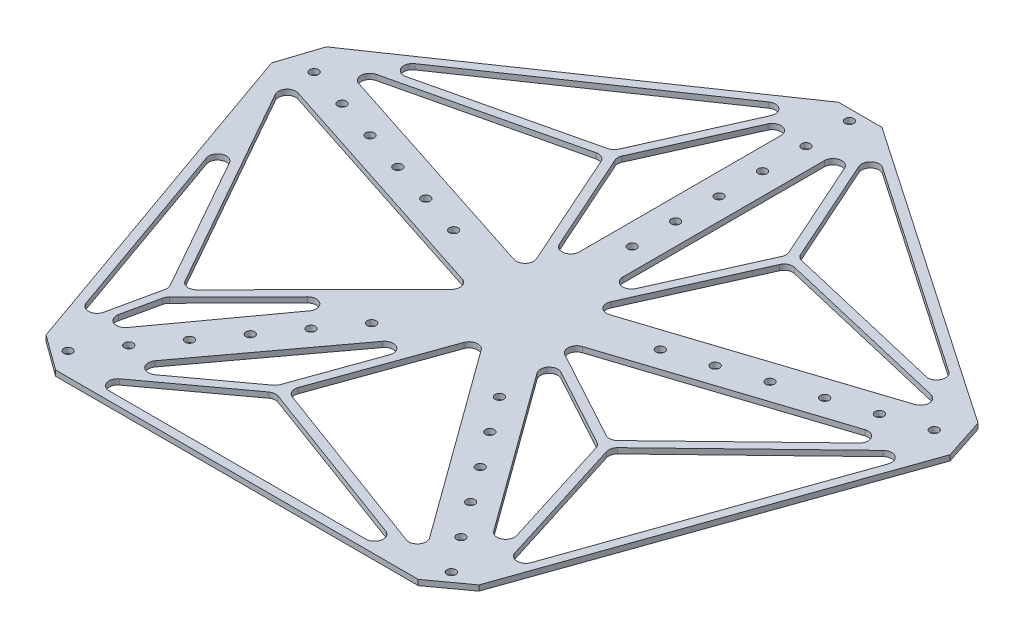
from build123d import *

# Parameters (mm, degrees)
BOSS_EXTRUDE2_DEPTH = 3.175
CUT_EXTRUDE6_START  = 3.175
SKETCH4_R           = 2.54
CUT_EXTRUDE6_DEPTH  = 4.175
CUT_EXTRUDE13_START = 3.175
CUT_EXTRUDE13_DEPTH = 4.175


with BuildPart() as part:
    # Sketch5 → Boss-Extrude2 (new body)
    with BuildSketch(Plane(origin=(0, 0, 0), x_dir=(1, 0, 0), z_dir=(0, 1, 0))):
        Polygon((-12.7, 196.799011925), (12.7, 196.799011925), (190.398728244, 75.217867192), (198.247759901, 51.061031678), (126.494099545, -152.497661128), (105.945067888, -167.427406536), (-105.945067888, -167.427406536), (-126.494099545, -152.497661128), (-198.247759901, 51.061031678), (-190.398728244, 75.217867192), align=None)
    extrude(amount=BOSS_EXTRUDE2_DEPTH)

    # Sketch4 → Cut-Extrude6 (cut, through all)
    with BuildSketch(Plane(origin=(0, 0, 0), x_dir=(1, 0, 0), z_dir=(0, 1, 0)).offset(CUT_EXTRUDE6_START)):
        with Locations((0, 63.5)):
            Circle(SKETCH4_R)
        with Locations((60.392088785, 19.622579143)):
            Circle(SKETCH4_R)
        with Locations((37.324363521, -51.372579143)):
            Circle(SKETCH4_R)
        with Locations((-37.324363521, -51.372579143)):
            Circle(SKETCH4_R)
        with Locations((-60.392088785, 19.622579143)):
            Circle(SKETCH4_R)
        with Locations((0, 88.9)):
            Circle(SKETCH4_R)
        with Locations((0, 114.3)):
            Circle(SKETCH4_R)
        with Locations((0, 139.7)):
            Circle(SKETCH4_R)
        with Locations((0, 165.1)):
            Circle(SKETCH4_R)
        with Locations((0, 190.5)):
            Circle(SKETCH4_R)
        with Locations((84.548924299, 27.4716108)):
            Circle(SKETCH4_R)
        with Locations((108.705759813, 35.320642457)):
            Circle(SKETCH4_R)
        with Locations((132.862595326, 43.169674114)):
            Circle(SKETCH4_R)
        with Locations((157.01943084, 51.018705771)):
            Circle(SKETCH4_R)
        with Locations((181.176266354, 58.867737428)):
            Circle(SKETCH4_R)
        with Locations((52.254108929, -71.9216108)):
            Circle(SKETCH4_R)
        with Locations((67.183854337, -92.470642457)):
            Circle(SKETCH4_R)
        with Locations((82.113599745, -113.019674114)):
            Circle(SKETCH4_R)
        with Locations((97.043345153, -133.568705771)):
            Circle(SKETCH4_R)
        with Locations((111.973090562, -154.117737428)):
            Circle(SKETCH4_R)
        with Locations((-52.254108929, -71.9216108)):
            Circle(SKETCH4_R)
        with Locations((-67.183854337, -92.470642457)):
            Circle(SKETCH4_R)
        with Locations((-82.113599745, -113.019674114)):
            Circle(SKETCH4_R)
        with Locations((-97.043345153, -133.568705771)):
            Circle(SKETCH4_R)
        with Locations((-111.973090562, -154.117737428)):
            Circle(SKETCH4_R)
        with Locations((-84.548924299, 27.4716108)):
            Circle(SKETCH4_R)
        with Locations((-108.705759813, 35.320642457)):
            Circle(SKETCH4_R)
        with Locations((-132.862595326, 43.169674114)):
            Circle(SKETCH4_R)
        with Locations((-157.01943084, 51.018705771)):
            Circle(SKETCH4_R)
        with Locations((-181.176266354, 58.867737428)):
            Circle(SKETCH4_R)
    extrude(amount=-CUT_EXTRUDE6_DEPTH, mode=Mode.SUBTRACT)

    # Sketch7 → Cut-Extrude13 (cut, through all)
    with BuildSketch(Plane(origin=(0, 0, 0), x_dir=(1, 0, 0), z_dir=(0, 1, 0)).offset(CUT_EXTRUDE13_START)):
        with BuildLine():
            Line((-156.047041019, 92.565980885), (-33.192300571, 176.622969516))
            ThreePointArc((-33.192300571, 176.622969516), (-27.068067962, 176.329998491), (-25.68635922, 170.356478756))
            Line((-25.68635922, 170.356478756), (-53.203019711, 108.827512556))
            ThreePointArc((-53.203019711, 108.827512556), (-54.602287787, 106.987211346), (-56.672188684, 105.957565789))
            Line((-56.672188684, 105.957565789), (-152.01026864, 83.429543359))
            ThreePointArc((-152.01026864, 83.429543359), (-157.825138498, 86.320353355), (-156.047041019, 92.565980885))
        make_face()
        with BuildLine():
            Line((-162.317570458, 66.093745934), (-27.928166645, 22.427981671))
            ThreePointArc((-27.928166645, 22.427981671), (-22.580875797, 23.862731232), (-21.720361584, 29.331875681))
            Line((-21.720361584, 29.331875681), (-52.204230458, 97.55011911))
            ThreePointArc((-52.204230458, 97.55011911), (-54.590345473, 100.031208318), (-58.010442561, 100.421444699))
            Line((-58.010442561, 100.421444699), (-161.9159775, 75.868965534))
            ThreePointArc((-161.9159775, 75.868965534), (-165.823482552, 71.133637537), (-162.317570458, 66.093745934))
        make_face()
        with BuildLine():
            Line((-12.7, 45.417267794), (-12.7, 163.148827455))
            ThreePointArc((-12.7, 163.148827455), (-16.719693987, 168.116940895), (-22.417382346, 165.222733185))
            Line((-22.417382346, 165.222733185), (-48.732523081, 106.380439974))
            ThreePointArc((-48.732523081, 106.380439974), (-49.175140679, 104.307289406), (-48.733139465, 102.234007335))
            Line((-48.733139465, 102.234007335), (-22.41799873, 43.344740886))
            ThreePointArc((-22.41799873, 43.344740886), (-16.720432528, 40.44899679), (-12.7, 45.417267794))
        make_face()
        with BuildLine():
            Line((162.102822693, 75.93291253), (57.996487946, 100.40450036))
            ThreePointArc((57.996487946, 100.40450036), (54.579506885, 100.011587225), (52.196050577, 97.531813783))
            Line((52.196050577, 97.531813783), (21.720361584, 29.331875681))
            ThreePointArc((21.720361584, 29.331875681), (22.580875797, 23.862731232), (27.928166645, 22.427981671))
            Line((27.928166645, 22.427981671), (162.510190385, 66.156331943))
            ThreePointArc((162.510190385, 66.156331943), (166.015979846, 71.199187482), (162.102822693, 75.93291253))
        make_face()
        with BuildLine():
            Line((48.733139465, 102.234007335), (22.41799873, 43.344740886))
            ThreePointArc((22.41799873, 43.344740886), (16.720432528, 40.44899679), (12.7, 45.417267794))
            Line((12.7, 45.417267794), (12.7, 163.148827455))
            ThreePointArc((12.7, 163.148827455), (16.719693987, 168.116940895), (22.417382346, 165.222733185))
            Line((22.417382346, 165.222733185), (48.732523081, 106.380439974))
            ThreePointArc((48.732523081, 106.380439974), (49.175140679, 104.307289406), (48.733139465, 102.234007335))
        make_face()
        with BuildLine():
            Line((151.806255709, 83.571718708), (56.689611273, 105.93015947))
            ThreePointArc((56.689611273, 105.93015947), (54.616221901, 106.95927578), (53.214667567, 108.801467224))
            Line((53.214667567, 108.801467224), (25.68635922, 170.356478756))
            ThreePointArc((25.68635922, 170.356478756), (27.068067962, 176.329998491), (33.192300571, 176.622969516))
            Line((33.192300571, 176.622969516), (155.837253354, 92.709517222))
            ThreePointArc((155.837253354, 92.709517222), (157.616548918, 86.466603462), (151.806255709, 83.571718708))
        make_face()
        with BuildLine():
            Line((-109.675191072, -97.278148196), (-69.427772609, -56.769451369))
            ThreePointArc((-69.427772609, -56.769451369), (-62.531124292, -56.481718848), (-61.714260801, -63.335862269))
            Line((-61.714260801, -63.335862269), (-106.556562877, -125.055996119))
            ThreePointArc((-106.556562877, -125.055996119), (-112.741607686, -126.706833129), (-115.631215695, -120.99454745))
            Line((-115.631215695, -120.99454745), (-111.036332082, -99.783110428))
            ThreePointArc((-111.036332082, -99.783110428), (-110.535086119, -98.433188327), (-109.675191072, -97.278148196))
        make_face()
        with BuildLine():
            Line((-160.01287172, -11.797453126), (-115.302741252, -91.137833587))
            ThreePointArc((-115.302741252, -91.137833587), (-114.705391008, -92.873056917), (-114.763562547, -94.707298829))
            Line((-114.763562547, -94.707298829), (-121.136405831, -124.126360411))
            ThreePointArc((-121.136405831, -124.126360411), (-125.782514064, -128.120851546), (-130.892311968, -124.739691019))
            Line((-130.892311968, -124.739691019), (-169.229599152, -15.980248976))
            ThreePointArc((-169.229599152, -15.980248976), (-166.537902044, -9.66550515), (-160.01287172, -11.797453126))
        make_face()
        with BuildLine():
            Line((-181.26952666, 36.271088906), (-113.225686268, -84.476136124))
            ThreePointArc((-113.225686268, -84.476136124), (-109.481211548, -87.016291645), (-105.19631301, -85.562632288))
            Line((-105.19631301, -85.562632288), (-31.110697077, -10.996067034))
            ThreePointArc((-31.110697077, -10.996067034), (-29.776688248, -6.221713494), (-33.144596222, -2.584238112))
            Line((-33.144596222, -2.584238112), (-175.274052547, 43.596421663))
            ThreePointArc((-175.274052547, 43.596421663), (-180.775030607, 41.982551855), (-181.26952666, 36.271088906))
        make_face()
        with BuildLine():
            Line((-74.453831157, -140.756019196), (-34.711938953, -111.557421731))
            ThreePointArc((-34.711938953, -111.557421731), (-33.647034148, -110.499951242), (-32.937574876, -109.177478701))
            Line((-32.937574876, -109.177478701), (-16.052111409, -62.063826538))
            ThreePointArc((-16.052111409, -62.063826538), (-18.437808808, -55.870689617), (-24.913773623, -57.322714655))
            Line((-24.913773623, -57.322714655), (-81.541129293, -133.634964282))
            ThreePointArc((-81.541129293, -133.634964282), (-81.062237605, -140.245720888), (-74.453831157, -140.756019196))
        make_face()
        with BuildLine():
            Line((70.348704527, -162.347406536), (-79.76753394, -162.347406536))
            ThreePointArc((-79.76753394, -162.347406536), (-84.594706529, -158.850064045), (-82.77531384, -153.173550154))
            Line((-82.77531384, -153.173550154), (-32.545760735, -116.269607724))
            ThreePointArc((-32.545760735, -116.269607724), (-30.246199789, -115.333073871), (-27.777447331, -115.598286062))
            Line((-27.777447331, -115.598286062), (72.109238031, -152.502228493))
            ThreePointArc((72.109238031, -152.502228493), (75.349379704, -158.161636803), (70.348704527, -162.347406536))
        make_face()
        with BuildLine():
            Line((88.307338376, -143.151154518), (8.223559836, -32.925289612))
            ThreePointArc((8.223559836, -32.925289612), (3.394359174, -30.882434482), (-0.668390474, -34.197325343))
            Line((-0.668390474, -34.197325343), (-26.189671043, -105.406548465))
            ThreePointArc((-26.189671043, -105.406548465), (-26.011472491, -109.267573019), (-23.168060569, -111.885639858))
            Line((-23.168060569, -111.885639858), (82.436998541, -150.902281642))
            ThreePointArc((82.436998541, -150.902281642), (88.247194207, -149.204127624), (88.307338376, -143.151154518))
        make_face()
        with BuildLine():
            Line((120.811781369, -125.829494165), (96.262398583, -47.665479541))
            ThreePointArc((96.262398583, -47.665479541), (96.186283562, -44.888905977), (97.581871278, -42.487346237))
            Line((97.581871278, -42.487346237), (176.533018585, 33.681561215))
            ThreePointArc((176.533018585, 33.681561215), (182.806221583, 34.299417584), (184.851185291, 28.336788484))
            Line((184.851185291, 28.336788484), (130.449420769, -125.996133592))
            ThreePointArc((130.449420769, -125.996133592), (125.570538599, -129.386544207), (120.811781369, -125.829494165))
        make_face()
        with BuildLine():
            Line((36.031884039, -1.646101431), (160.686191034, 38.856538132))
            ThreePointArc((160.686191034, 38.856538132), (166.611036143, 36.640517516), (165.78310442, 30.369228493))
            Line((165.78310442, 30.369228493), (94.004694269, -38.879709189))
            ThreePointArc((94.004694269, -38.879709189), (91.160058898, -40.257714647), (88.051207215, -39.686846319))
            Line((88.051207215, -39.686846319), (35.17531037, -10.940548199))
            ThreePointArc((35.17531037, -10.940548199), (32.543127187, -6.011272736), (36.031884039, -1.646101431))
        make_face()
        with BuildLine():
            Line((112.545493489, -116.463504213), (91.315714754, -48.868943893))
            ThreePointArc((91.315714754, -48.868943893), (90.391658778, -47.163100082), (88.895515005, -45.928054997))
            Line((88.895515005, -45.928054997), (42.812793964, -20.874907603))
            ThreePointArc((42.812793964, -20.874907603), (36.567973396, -21.987478108), (36.276607633, -28.32393635))
            Line((36.276607633, -28.32393635), (103.589107409, -120.971644063))
            ThreePointArc((103.589107409, -120.971644063), (109.982888345, -122.523300077), (112.545493489, -116.463504213))
        make_face()
    extrude(amount=-CUT_EXTRUDE13_DEPTH, mode=Mode.SUBTRACT)


solid = part.part
